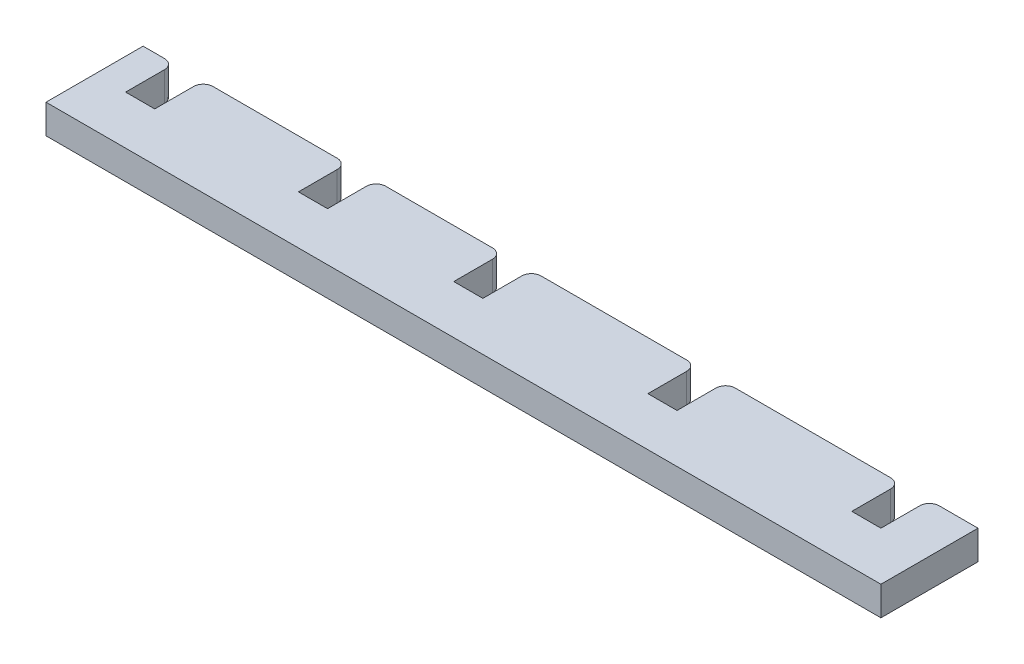
from build123d import *

# Parameters (mm, degrees)
SKETCH1_W           = 86
SKETCH1_H           = 3
BOSS_EXTRUDE1_DEPTH = 10
SKETCH3_W           = 3
SKETCH3_H           = 3
CUT_EXTRUDE2_DEPTH  = 5
FILLET2_R           = 1


with BuildPart() as part:
    # Sketch1 → Boss-Extrude1 (new body)
    with BuildSketch(Plane.XY):
        with Locations((43, 1.5)):
            Rectangle(SKETCH1_W, SKETCH1_H)
    extrude(amount=BOSS_EXTRUDE1_DEPTH)

    # Sketch3 → Cut-Extrude2 (cut)
    with BuildSketch(Plane(origin=(0, 0, 0), x_dir=(-1, 0, 0), z_dir=(0, 0, -1))):
        with Locations((-79.5, 1.5)):
            Rectangle(SKETCH3_W, SKETCH3_H)
        with Locations((-58.5, 1.5)):
            Rectangle(SKETCH3_W, SKETCH3_H)
        with Locations((-38.5, 1.5)):
            Rectangle(SKETCH3_W, SKETCH3_H)
        with Locations((-22.5, 1.5)):
            Rectangle(SKETCH3_W, SKETCH3_H)
        with Locations((-4.7, 1.5)):
            Rectangle(SKETCH3_W, SKETCH3_H)
    extrude(amount=-CUT_EXTRUDE2_DEPTH, mode=Mode.SUBTRACT)

    # Fillet2
    fillet2_edges = [part.edges().sort_by_distance(p)[0] for p in [
        (78, 1.5, 0),
        (81, 1.5, 0),
        (57, 1.5, 0),
        (60, 1.5, 0),
        (37, 1.5, 0),
        (40, 1.5, 0),
        (21, 1.5, 0),
        (24, 1.5, 0),
        (3.2, 1.5, 0),
        (6.2, 1.5, 0),
    ]]
    fillet(fillet2_edges, radius=FILLET2_R)


solid = part.part
